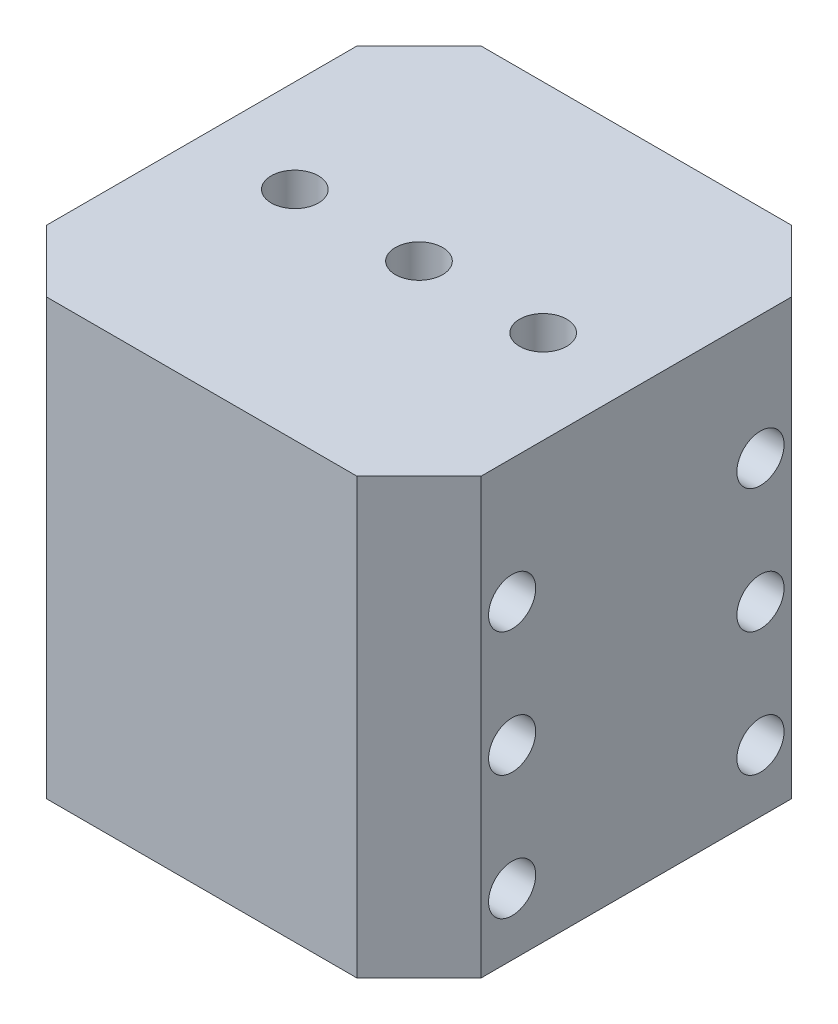
from build123d import *

# Parameters (mm, degrees)
SKETCH1_R           = 2.413
BOSS_EXTRUDE1_DEPTH = 44.45
SKETCH2_R           = 2.413
CUT_EXTRUDE1_DEPTH  = 50.8


with BuildPart() as part:
    # Sketch1 → Boss-Extrude1 (new body)
    with BuildSketch(Plane(origin=(0, 0, 0), x_dir=(1, 0, 0), z_dir=(0, 1, 0))):
        Polygon((0, 38.1), (6.35, 44.45), (38.1, 44.45), (44.45, 38.1), (44.45, 6.35), (38.1, 0), (6.35, 0), (0, 6.35), align=None)
        with Locations((9.525, 22.225)):
            Circle(SKETCH1_R, mode=Mode.SUBTRACT)
        with Locations((22.225, 22.225)):
            Circle(SKETCH1_R, mode=Mode.SUBTRACT)
        with Locations((34.925, 22.225)):
            Circle(SKETCH1_R, mode=Mode.SUBTRACT)
    extrude(amount=BOSS_EXTRUDE1_DEPTH)

    # Sketch2 → Cut-Extrude1 (cut)
    with BuildSketch(Plane(origin=(44.45, 0, 0), x_dir=(0, 0, -1), z_dir=(1, 0, 0))):
        with Locations((9.525, 31.75)):
            Circle(SKETCH2_R)
        with Locations((34.925, 31.75)):
            Circle(SKETCH2_R)
        with Locations((34.925, 6.35)):
            Circle(SKETCH2_R)
        with Locations((9.525, 6.35)):
            Circle(SKETCH2_R)
        with Locations((9.525, 19.05)):
            Circle(SKETCH2_R)
        with Locations((34.925, 19.05)):
            Circle(SKETCH2_R)
    extrude(amount=-CUT_EXTRUDE1_DEPTH, mode=Mode.SUBTRACT)


solid = part.part
